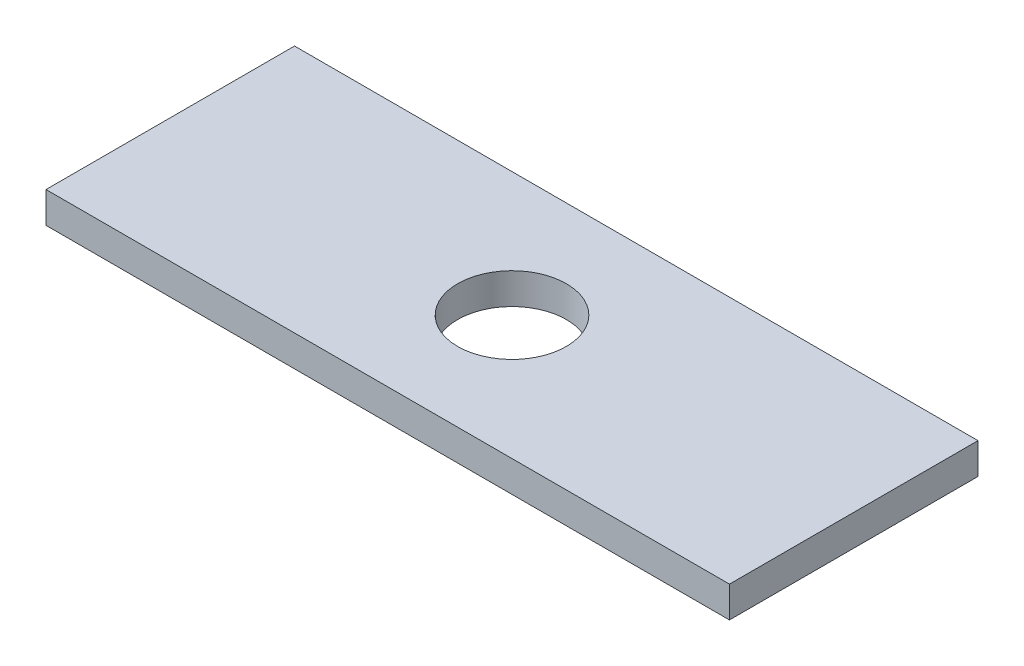
from build123d import *

# Parameters (mm, degrees)
SKETCH1_W           = 139.7
SKETCH1_H           = 50.8
BOSS_EXTRUDE1_DEPTH = 6.35
SKETCH2_R           = 11.1125
CUT_EXTRUDE1_DEPTH  = 7.35


with BuildPart() as part:
    # Sketch1 → Boss-Extrude1 (new body)
    with BuildSketch(Plane(origin=(0, 0, 0), x_dir=(1, 0, 0), z_dir=(0, 1, 0))):
        with Locations((69.85, -25.4)):
            Rectangle(SKETCH1_W, SKETCH1_H)
    extrude(amount=BOSS_EXTRUDE1_DEPTH)

    # Sketch2 → Cut-Extrude1 (cut, through all)
    with BuildSketch(Plane(origin=(0, 6.35, 0), x_dir=(1, 0, 0), z_dir=(0, 1, 0))):
        with Locations((69.85, -25.4)):
            Circle(SKETCH2_R)
    extrude(amount=-CUT_EXTRUDE1_DEPTH, mode=Mode.SUBTRACT)


solid = part.part
